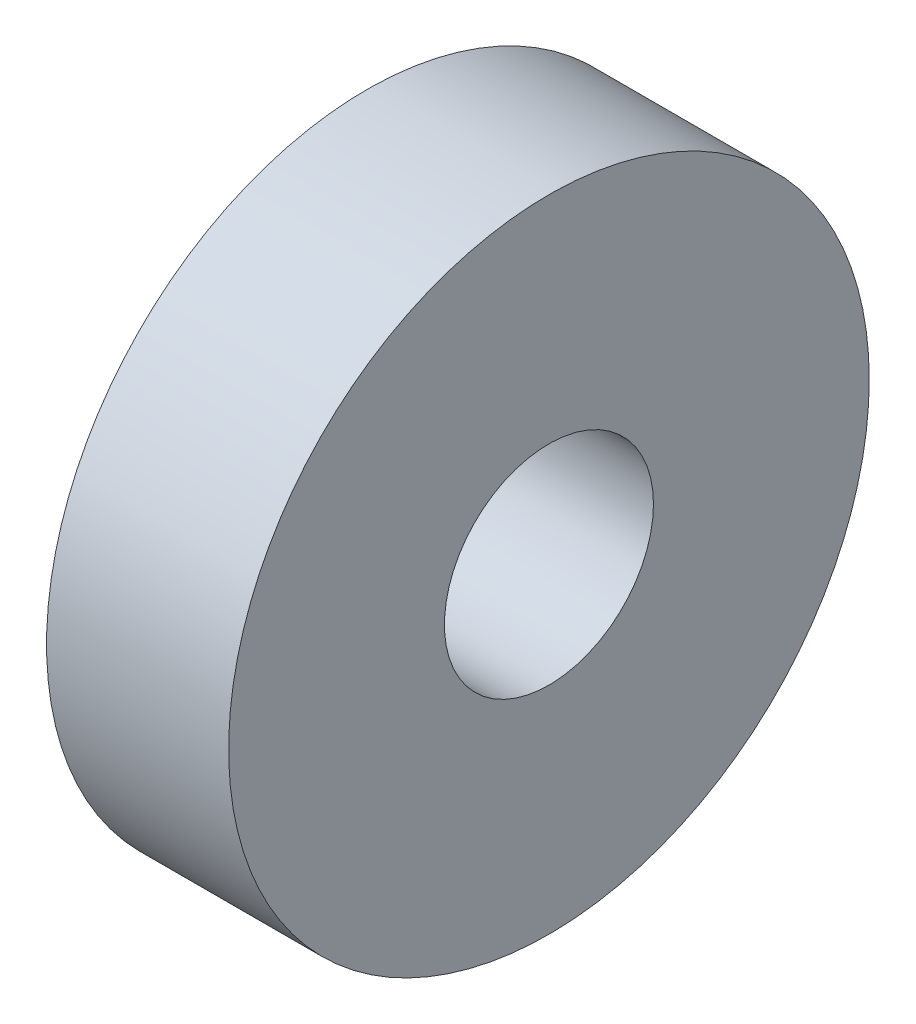
from build123d import *

# Parameters (mm, degrees)
SKETCH1_R           = 12.065
BOSS_EXTRUDE1_DEPTH = 3.429
SKETCH2_R           = 3.937
CUT_EXTRUDE1_DEPTH  = 7.858


with BuildPart() as part:
    # Sketch1 → Boss-Extrude1 (new body, symmetric)
    with BuildSketch(Plane(origin=(0, 0, 0), x_dir=(0, 0, -1), z_dir=(1, 0, 0))):
        Circle(SKETCH1_R)
    extrude(amount=BOSS_EXTRUDE1_DEPTH, both=True)

    # Sketch2 → Cut-Extrude1 (cut, through all)
    with BuildSketch(Plane(origin=(3.429, 0, 0), x_dir=(0, 0, -1), z_dir=(1, 0, 0))):
        Circle(SKETCH2_R)
    extrude(amount=-CUT_EXTRUDE1_DEPTH, mode=Mode.SUBTRACT)


solid = part.part
